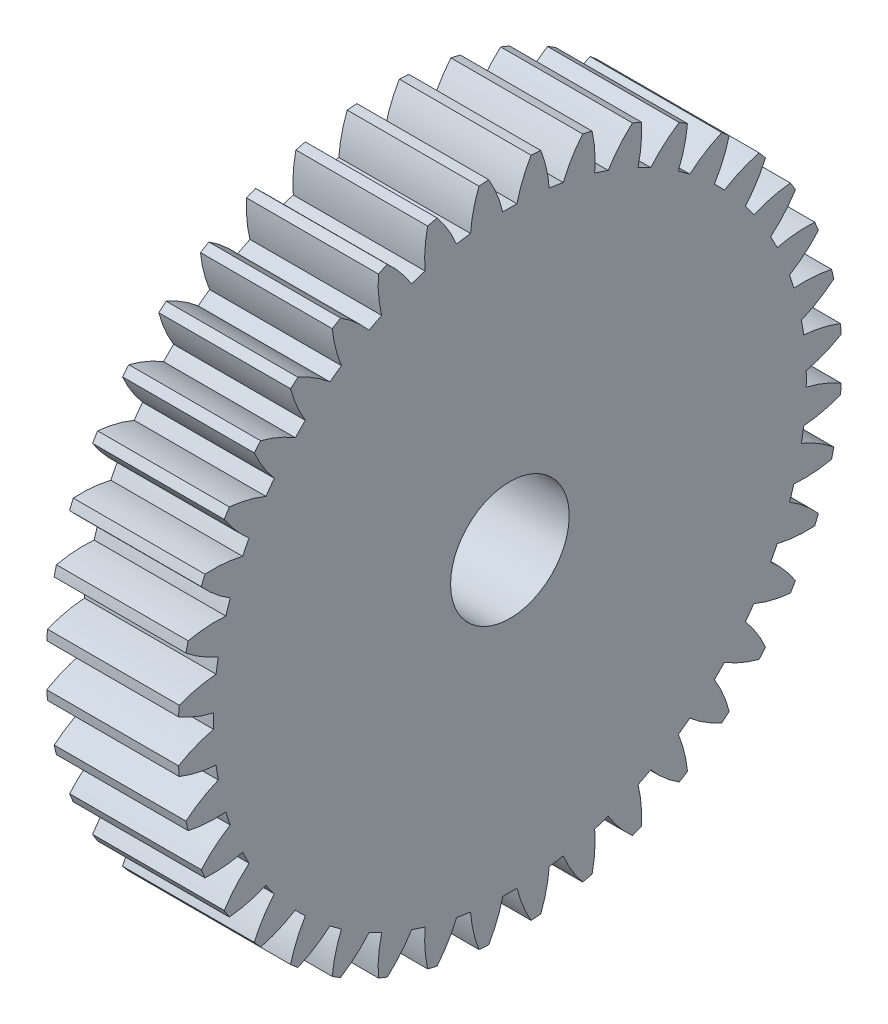
from build123d import *

# Parameters (mm, degrees)
BASPROSKE_W        = 5
BASPROSKE_H        = 12.6
TOOTHCUT_DEPTH     = 19.507295859
TEETHCUTS_COUNT    = 40
TEETHCUTS_ANGLE    = 351
BORSKE_R           = 0.4
BORE_DEPTH         = 50.0000508
SKETCH1_R          = 2.25
CUT_EXTRUDE1_DEPTH = 19.472291037


with BuildPart() as part:
    # BasProSke → Base-Revolve (revolve)
    with BuildSketch(Plane(origin=(0, 0, 0), x_dir=(1, 0, 0), z_dir=(0, 1, 0)), mode=Mode.PRIVATE) as base_revolve_sk:
        with Locations((2.5, 6.3)):
            Rectangle(BASPROSKE_W, BASPROSKE_H)
    revolve(base_revolve_sk.sketch.rotate(Axis((-10, 0, 0), (1, 0, 0)), 180), axis=Axis((-10, 0, 0), (1, 0, 0)))

    # TooCutSke → ToothCut (cut, through all)
    with BuildSketch(Plane(origin=(0, 0, 0), x_dir=(0, 0, -1), z_dir=(1, 0, 0))):
        with BuildLine():
            ThreePointArc((0.269437699, 11.245772731), (0, 11.249), (-0.269437699, 11.245772731))
            ThreePointArc((-0.269437699, 11.245772731), (-0.49248792, 11.943313622), (-0.81905568, 12.598804426))
            ThreePointArc((-0.81905568, 12.598804426), (0, 12.6254), (0.81905568, 12.598804426))
            ThreePointArc((0.81905568, 12.598804426), (0.49248792, 11.943313622), (0.269437699, 11.245772731))
        make_face()
    toothcut = extrude(amount=TOOTHCUT_DEPTH, mode=Mode.SUBTRACT)

    # TeethCuts: ToothCut ×40 about axis
    teethcuts_axis = Axis((-10, 0, 0), (1, 0, 0))
    for i in range(1, TEETHCUTS_COUNT):
        add(toothcut.rotate(teethcuts_axis, i * TEETHCUTS_ANGLE / (TEETHCUTS_COUNT - 1)), mode=Mode.SUBTRACT)

    # BorSke → Bore (cut, symmetric)
    with BuildSketch(Plane(origin=(0, 0, 0), x_dir=(0, 0, -1), z_dir=(1, 0, 0))):
        with Locations(Location((0, 0, 0), (0, 0, 180))):
            Circle(BORSKE_R)
    extrude(amount=BORE_DEPTH, both=True, mode=Mode.SUBTRACT)

    # Sketch1 → Cut-Extrude1 (cut, through all)
    with BuildSketch(Plane.ZY):
        Circle(SKETCH1_R)
    extrude(amount=-CUT_EXTRUDE1_DEPTH, mode=Mode.SUBTRACT)


solid = part.part
